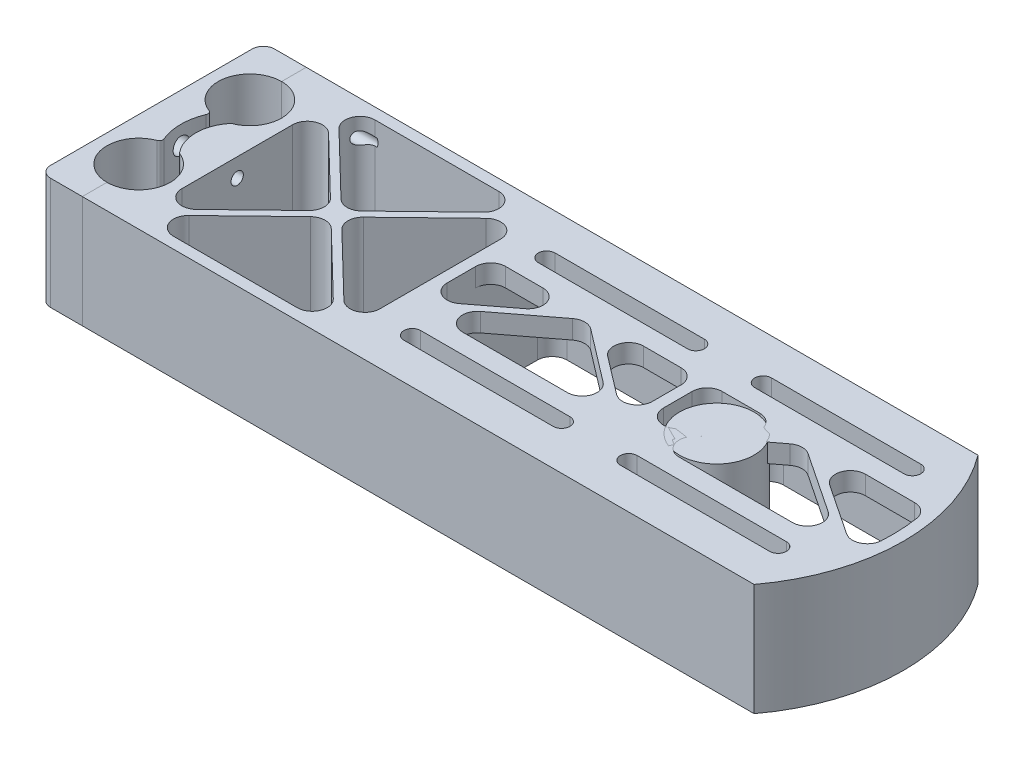
from build123d import *

# Parameters (mm, degrees)
EXTRUDE_1_DEPTH            = 30
CUT_EXTRUDE_1_DEPTH        = 31
TEMP_R                     = 10
EXTRUDE_2_DEPTH            = 30
EXTRUDE_3_DEPTH            = 5
EXTRUDE_4_DEPTH            = 30
SKETCH_6_W                 = 3
SKETCH_6_H                 = 54
EXTRUDE_5_DEPTH            = 30
EXTRUDE_6_DEPTH            = 30
SKETCH_9_W                 = 3
SKETCH_9_H                 = 54
EXTRUDE_8_DEPTH            = 25
EXTRUDE_8_DEPTH_BACK       = 5
EXTRUDE_7_DEPTH            = 5
FILLET_1_R                 = 4
FILLET_2_R                 = 4
FILLET_3_R                 = 4
EXTRUDE_9_DEPTH            = 5
CUT_EXTRUDE_4_DEPTH        = 31
EXTRUDE_10_DEPTH           = 30
FILLET_4_R                 = 4
M4X0_71_AT_2_COUNT         = 2
M4X0_71_AT_2_PITCH         = 25.75
M4X0_71_AT_3_COUNT         = 2
M4X0_71_AT_3_PITCH         = 51.5
M4X0_71_AT_4_COUNT         = 2
M4X0_71_AT_4_PITCH         = 55.247171873
M4X0_71_AT_5_COUNT         = 2
M4X0_71_AT_5_PITCH         = 32.60463924
M4X0_71_AT_6_COUNT         = 2
M4X0_71_AT_6_PITCH         = 20
EXTRUDE_11_DEPTH           = 30
EXTRUDE_12_DEPTH           = 30
CUT_EXTRUDE_6_DEPTH        = 31.0000001
FILLET_8_R                 = 1
FILLET_9_R                 = 1
HOLE_WIZARD_M41_AT_2_COUNT = 2
HOLE_WIZARD_M41_AT_2_PITCH = 20
FILLET_10_R                = 3


with BuildPart() as part:
    # Эскиз1 → Бобышка-Вытянуть1 (new body)
    with BuildSketch(Plane(origin=(0, 0, 0), x_dir=(1, 0, 0), z_dir=(0, 1, 0))):
        with BuildLine():
            Line((0, 60), (180, 60))
            ThreePointArc((180, 60), (190, 30), (180, 0))
            Line((180, 0), (0, 0))
            Line((0, 0), (0, 8))
            ThreePointArc((0, 8), (7.1, 15.1), (0, 22.2))
            Line((0, 22.2), (0, 37.8))
            ThreePointArc((0, 37.8), (7.1, 44.9), (0, 52))
            Line((0, 52), (0, 60))
        make_face()
    extrude(amount=EXTRUDE_1_DEPTH)

    # Эскиз2 → Вырез-Вытянуть1 (cut, through all)
    with BuildSketch(Plane(origin=(0, 30, 0), x_dir=(1, 0, 0), z_dir=(0, 1, 0))):
        with BuildLine():
            Line((3, 3), (178.470768123, 3))
            ThreePointArc((178.470768123, 3), (187, 30), (178.470768123, 57))
            Line((178.470768123, 57), (3, 57))
            Line((3, 57), (3, 54.544169223))
            ThreePointArc((3, 54.544169223), (10.1, 44.9), (3, 35.255830777))
            Line((3, 35.255830777), (3, 24.744169223))
            ThreePointArc((3, 24.744169223), (10.1, 15.1), (3, 5.455830777))
            Line((3, 5.455830777), (3, 3))
        make_face()
    extrude(amount=-CUT_EXTRUDE_1_DEPTH, mode=Mode.SUBTRACT)

    # Эскиз3 → Бобышка-Вытянуть3 (add)
    with BuildSketch(Plane(origin=(0, 30, 0), x_dir=(1, 0, 0), z_dir=(0, 1, 0))):
        with BuildLine():
            Line((178.470768123, 57), (68.916586692, 57))
            Line((68.916586692, 57), (68.916586692, 40.5))
            Line((68.916586692, 40.5), (185.812116301, 40.5))
            ThreePointArc((185.812116301, 40.5), (182.941397878, 49.105924428), (178.470768123, 57))
        make_face()
        with BuildLine():
            Line((116.416586692, 43.5), (76.416586692, 43.5))
            ThreePointArc((76.416586692, 43.5), (71.916586692, 48), (76.416586692, 52.5))
            Line((76.416586692, 52.5), (116.416586692, 52.5))
            ThreePointArc((116.416586692, 52.5), (120.916586692, 48), (116.416586692, 43.5))
        make_face(mode=Mode.SUBTRACT)
        with BuildLine():
            ThreePointArc((174.416586692, 52.5), (178.916586692, 48), (174.416586692, 43.5))
            Line((174.416586692, 43.5), (134.416586692, 43.5))
            ThreePointArc((134.416586692, 43.5), (129.916586692, 48), (134.416586692, 52.5))
            Line((134.416586692, 52.5), (174.416586692, 52.5))
        make_face(mode=Mode.SUBTRACT)
        with BuildLine():
            ThreePointArc((178.470768123, 3), (182.941397878, 10.894075572), (185.812116301, 19.5))
            Line((185.812116301, 19.5), (68.916586692, 19.5))
            Line((68.916586692, 19.5), (68.916586692, 3))
            Line((68.916586692, 3), (178.470768123, 3))
        make_face()
        with BuildLine():
            ThreePointArc((76.416586692, 7.5), (71.916586692, 12), (76.416586692, 16.5))
            Line((76.416586692, 16.5), (116.416586692, 16.5))
            ThreePointArc((116.416586692, 16.5), (120.916586692, 12), (116.416586692, 7.5))
            Line((116.416586692, 7.5), (76.416586692, 7.5))
        make_face(mode=Mode.SUBTRACT)
        with BuildLine():
            Line((134.416586692, 16.5), (174.416586692, 16.5))
            ThreePointArc((174.416586692, 16.5), (178.916586692, 12), (174.416586692, 7.5))
            Line((174.416586692, 7.5), (134.416586692, 7.5))
            ThreePointArc((134.416586692, 7.5), (129.916586692, 12), (134.416586692, 16.5))
        make_face(mode=Mode.SUBTRACT)
    extrude(amount=-EXTRUDE_3_DEPTH)

    # Эскиз4 → Бобышка-Вытянуть4 (add, through all)
    with BuildSketch(Plane(origin=(0, 30, 0), x_dir=(1, 0, 0), z_dir=(0, 1, 0))):
        with BuildLine():
            Line((10.1, 57), (3, 57))
            Line((3, 57), (3, 54.544169223))
            ThreePointArc((3, 54.544169223), (8.133572401, 50.887904475), (10.1, 44.9))
            Line((10.1, 44.9), (10.1, 57))
        make_face()
        with BuildLine():
            Line((10.1, 15.099999916), (10.1, 44.9))
            ThreePointArc((10.1, 44.9), (8.133572401, 38.912095525), (3, 35.255830777))
            Line((3, 35.255830777), (3, 24.744169223))
            ThreePointArc((3, 24.744169223), (8.133572426, 21.087904441), (10.1, 15.099999916))
        make_face()
        with BuildLine():
            Line((10.1, 3), (10.1, 15.099999916))
            ThreePointArc((10.1, 15.099999916), (8.133572376, 9.112095491), (3, 5.455830777))
            Line((3, 5.455830777), (3, 3))
            Line((3, 3), (10.1, 3))
        make_face()
    extrude(amount=-EXTRUDE_4_DEPTH)

    # Эскиз6 → Бобышка-Вытянуть5 (add, through all)
    with BuildSketch(Plane(origin=(0, 30, 0), x_dir=(1, 0, 0), z_dir=(0, 1, 0))):
        with Locations((67.416586692, 30)):
            Rectangle(SKETCH_6_W, SKETCH_6_H)
    extrude(amount=-EXTRUDE_5_DEPTH)

    # Эскиз7 → Бобышка-Вытянуть6 (add, through all)
    with BuildSketch(Plane(origin=(0, 30, 0), x_dir=(1, 0, 0), z_dir=(0, 1, 0))):
        Polygon((10.1, 55.608609353), (36.57009563, 30), (10.1, 4.391390647), (10.1, 3), (11.538197716, 3), (38.008293346, 28.608609353), (64.478388976, 3), (65.916586692, 3), (65.916586692, 4.391390647), (39.446491062, 30), (65.916586692, 55.608609353), (65.916586692, 57), (64.478388976, 57), (38.008293346, 31.391390647), (11.538197716, 57), (10.1, 57), align=None)
    extrude(amount=-EXTRUDE_6_DEPTH)

    # Эскиз9 → Бобышка-Вытянуть8 (add, two sides)
    with BuildSketch(Plane.XZ.offset(-25)) as extrude_8_sk:
        with Locations((125.416586692, -30)):
            Rectangle(SKETCH_9_W, SKETCH_9_H)
    extrude(amount=EXTRUDE_8_DEPTH)
    extrude(extrude_8_sk.sketch, amount=-EXTRUDE_8_DEPTH_BACK)

    # Эскиз8 → Бобышка-Вытянуть7 (add)
    with BuildSketch(Plane(origin=(0, 30, 0), x_dir=(1, 0, 0), z_dir=(0, 1, 0))):
        Polygon((70.564267671, 19.5), (96.416586692, 39.241770889), (122.268905713, 19.5), (123.916586692, 19.5), (123.916586692, 20.758229111), (98.064267671, 40.5), (94.768905713, 40.5), (68.916586692, 20.758229111), (68.916586692, 19.5), align=None)
        with BuildLine():
            Line((128.569887735, 19.5), (154.477979009, 39.178204914))
            Line((154.477979009, 39.178204914), (184.008770478, 19.5))
            Line((184.008770478, 19.5), (185.812116301, 19.5))
            ThreePointArc((185.812116301, 19.5), (185.929117822, 20.024222532), (186.040120933, 20.549747915))
            Line((186.040120933, 20.549747915), (156.101072293, 40.5))
            Line((156.101072293, 40.5), (152.911636662, 40.5))
            Line((152.911636662, 40.5), (126.916586692, 20.755746568))
            Line((126.916586692, 20.755746568), (126.916586692, 19.5))
            Line((126.916586692, 19.5), (128.569887735, 19.5))
        make_face()
    extrude(amount=-EXTRUDE_7_DEPTH)

    # Скругление1
    fillet_1_edges = [part.edges().sort_by_distance(p)[0] for p in [
        (36.57009563, 15, -30),
        (11.538197716, 15, -57),
        (38.008293346, 15, -31.391390647),
        (64.478388976, 15, -57),
        (65.916586692, 15, -55.608609353),
        (39.446491062, 15, -30),
        (65.916586692, 15, -4.391390647),
        (64.478388976, 15, -3),
        (38.008293346, 15, -28.608609353),
        (11.538197716, 15, -3),
    ]]
    fillet(fillet_1_edges, radius=FILLET_1_R)

    # Скругление2
    fillet_2_edges = [part.edges().sort_by_distance(p)[0] for p in [
        (68.916586692, 12.5, -57),
        (68.916586692, 12.5, -3),
        (123.916586692, 12.5, -57),
        (126.916586692, 12.5, -3),
        (123.916586692, 12.5, -3),
        (126.916586692, 12.5, -57),
        (178.470768123, 12.5, -57),
        (178.470768123, 12.5, -3),
    ]]
    fillet(fillet_2_edges, radius=FILLET_2_R)

    # Скругление3
    fillet_3_edges = [part.edges().sort_by_distance(p)[0] for p in [
        (123.916586692, 27.5, -40.5),
        (126.916586692, 27.5, -40.5),
        (70.564267671, 27.5, -19.5),
        (68.916586692, 27.5, -20.758229111),
        (94.768905713, 27.5, -40.5),
        (98.064267671, 27.5, -40.5),
        (123.916586692, 27.5, -20.758229111),
        (122.268905713, 27.5, -19.5),
        (96.416586692, 27.5, -39.241770889),
        (128.569887735, 27.5, -19.5),
        (126.916586692, 27.5, -20.755746568),
        (152.911636662, 27.5, -40.5),
        (156.101072293, 27.5, -40.5),
        (186.040120933, 27.5, -20.549747915),
        (184.008770478, 27.5, -19.5),
        (154.477979009, 27.5, -39.178204914),
        (68.916586692, 27.5, -40.5),
        (185.812116301, 27.5, -40.5),
    ]]
    fillet(fillet_3_edges, radius=FILLET_3_R)

    # Эскиз10 → Бобышка-Вытянуть9 (add)
    with BuildSketch(Plane(origin=(0, 30, 0), x_dir=(1, 0, 0), z_dir=(0, 1, 0))):
        with BuildLine():
            Line((76.416586692, 52.5), (116.416586692, 52.5))
            ThreePointArc((116.416586692, 52.5), (120.916586692, 48), (116.416586692, 43.5))
            Line((116.416586692, 43.5), (76.416586692, 43.5))
            ThreePointArc((76.416586692, 43.5), (71.916586692, 48), (76.416586692, 52.5))
        make_face()
        with BuildLine():
            Line((116.416586692, 50.25), (76.416586692, 50.25))
            ThreePointArc((76.416586692, 50.25), (74.166586692, 48), (76.416586692, 45.75))
            Line((76.416586692, 45.75), (116.416586692, 45.75))
            ThreePointArc((116.416586692, 45.75), (118.666586692, 48), (116.416586692, 50.25))
        make_face(mode=Mode.SUBTRACT)
        with BuildLine():
            Line((174.416586692, 52.5), (134.416586692, 52.5))
            ThreePointArc((134.416586692, 52.5), (129.916586692, 48), (134.416586692, 43.5))
            Line((134.416586692, 43.5), (174.416586692, 43.5))
            ThreePointArc((174.416586692, 43.5), (178.916586692, 48), (174.416586692, 52.5))
        make_face()
        with BuildLine():
            Line((174.416586692, 45.75), (134.416586692, 45.75))
            ThreePointArc((134.416586692, 45.75), (132.166586692, 48), (134.416586692, 50.25))
            Line((134.416586692, 50.25), (174.416586692, 50.25))
            ThreePointArc((174.416586692, 50.25), (176.666586692, 48), (174.416586692, 45.75))
        make_face(mode=Mode.SUBTRACT)
        with BuildLine():
            Line((76.416586692, 16.5), (116.416586692, 16.5))
            ThreePointArc((116.416586692, 16.5), (120.916586692, 12), (116.416586692, 7.5))
            Line((116.416586692, 7.5), (76.416586692, 7.5))
            ThreePointArc((76.416586692, 7.5), (71.916586692, 12), (76.416586692, 16.5))
        make_face()
        with BuildLine():
            Line((76.416586692, 9.75), (116.416586692, 9.75))
            ThreePointArc((116.416586692, 9.75), (118.666586692, 12), (116.416586692, 14.25))
            Line((116.416586692, 14.25), (76.416586692, 14.25))
            ThreePointArc((76.416586692, 14.25), (74.166586692, 12), (76.416586692, 9.75))
        make_face(mode=Mode.SUBTRACT)
        with BuildLine():
            Line((174.416586692, 16.5), (134.416586692, 16.5))
            ThreePointArc((134.416586692, 16.5), (129.916586692, 12), (134.416586692, 7.5))
            Line((134.416586692, 7.5), (174.416586692, 7.5))
            ThreePointArc((174.416586692, 7.5), (178.916586692, 12), (174.416586692, 16.5))
        make_face()
        with BuildLine():
            Line((174.416586692, 14.25), (134.416586692, 14.25))
            ThreePointArc((134.416586692, 14.25), (132.166586692, 12), (134.416586692, 9.75))
            Line((134.416586692, 9.75), (174.416586692, 9.75))
            ThreePointArc((174.416586692, 9.75), (176.666586692, 12), (174.416586692, 14.25))
        make_face(mode=Mode.SUBTRACT)
    extrude(amount=-EXTRUDE_9_DEPTH)

    # Эскиз16 → Вырез-Вытянуть4 (cut, through all)
    with BuildSketch(Plane(origin=(0, 30, 0), x_dir=(1, 0, 0), z_dir=(0, 1, 0))):
        with BuildLine():
            Line((0, 8), (0, 6.6))
            ThreePointArc((0, 6.6), (8.5, 15.1), (0, 23.6))
            Line((0, 23.6), (0, 22.2))
            ThreePointArc((0, 22.2), (7.1, 15.1), (0, 8))
        make_face()
        with BuildLine():
            Line((0, 37.8), (0, 36.4))
            ThreePointArc((0, 36.4), (8.5, 44.9), (0, 53.4))
            Line((0, 53.4), (0, 52))
            ThreePointArc((0, 52), (7.1, 44.9), (0, 37.8))
        make_face()
    extrude(amount=-CUT_EXTRUDE_4_DEPTH, mode=Mode.SUBTRACT)

    # Эскиз17 → Бобышка-Вытянуть10 (add, through all)
    with BuildSketch(Plane(origin=(0, 30, 0), x_dir=(1, 0, 0), z_dir=(0, 1, 0))):
        Polygon((11.5, 54.254173253), (11.5, 5.745826747), (10.1, 4.391390647), (10.1, 55.608609353), align=None)
    extrude(amount=-EXTRUDE_10_DEPTH)

    # Скругление4
    fillet_4_edges = [part.edges().sort_by_distance(p)[0] for p in [
        (11.5, 15, -54.254173253),
        (11.5, 15, -5.745826747),
    ]]
    fillet(fillet_4_edges, radius=FILLET_4_R)

    # Эскиз14 → Отверстие обработанное метчиком M4x0.71 (revolve, cut)
    with BuildSketch(Plane(origin=(0, 25, -55.75), x_dir=(0, 0, 1), z_dir=(0, 1, 0))):
        Polygon((0, 0), (0, 22.991420021), (1.65, 22), (1.65, 0), align=None)
    m4x0_71 = revolve(axis=Axis((-6.35, 25, -55.75), (1, 0, 0)), mode=Mode.SUBTRACT)

    # Отверстие обработанное метчиком M4x0.71 at 2: Отверстие обработанное метчиком M4x0.71 ×2
    with Locations(*[(0, 0, i * M4X0_71_AT_2_PITCH) for i in range(1, M4X0_71_AT_2_COUNT)]):
        add(m4x0_71, mode=Mode.SUBTRACT)

    # Отверстие обработанное метчиком M4x0.71 at 3: Отверстие обработанное метчиком M4x0.71 ×2
    with Locations(*[(0, 0, i * M4X0_71_AT_3_PITCH) for i in range(1, M4X0_71_AT_3_COUNT)]):
        add(m4x0_71, mode=Mode.SUBTRACT)

    # Отверстие обработанное метчиком M4x0.71 at 4: Отверстие обработанное метчиком M4x0.71 ×2
    with Locations(*[Vector(0, -0.362009481, 0.932174413) * (i * M4X0_71_AT_4_PITCH) for i in range(1, M4X0_71_AT_4_COUNT)]):
        add(m4x0_71, mode=Mode.SUBTRACT)

    # Отверстие обработанное метчиком M4x0.71 at 5: Отверстие обработанное метчиком M4x0.71 ×2
    with Locations(*[Vector(0, -0.613409639, 0.789764911) * (i * M4X0_71_AT_5_PITCH) for i in range(1, M4X0_71_AT_5_COUNT)]):
        add(m4x0_71, mode=Mode.SUBTRACT)

    # Отверстие обработанное метчиком M4x0.71 at 6: Отверстие обработанное метчиком M4x0.71 ×2
    with Locations(*[(0, -i * M4X0_71_AT_6_PITCH, 0) for i in range(1, M4X0_71_AT_6_COUNT)]):
        add(m4x0_71, mode=Mode.SUBTRACT)


with BuildPart() as body_2:
    # Temp → Бобышка-Вытянуть2 (new body)
    with BuildSketch(Plane(origin=(0, 30, 0), x_dir=(1, 0, 0), z_dir=(0, 1, 0))):
        with Locations((140, 30)):
            Circle(TEMP_R)
    extrude(amount=-EXTRUDE_2_DEPTH)


with BuildPart() as body_3:
    # Эскиз18 → Бобышка-Вытянуть11 (new body, through all)
    with BuildSketch(Plane.XZ):
        with BuildLine():
            Line((0, -6.6), (0, 0))
            Line((0, 0), (-11.5, 0))
            Line((-11.5, 0), (-11.5, -15.1))
            ThreePointArc((-11.5, -15.1), (-10.173494975, -20.461902647), (-6.5, -24.586832981))
            Line((-6.5, -24.586832981), (-6.5, -35.413167019))
            ThreePointArc((-6.5, -35.413167019), (-10.173494975, -39.538097353), (-11.5, -44.9))
            Line((-11.5, -44.9), (-11.5, -60))
            Line((-11.5, -60), (0, -60))
            Line((0, -60), (0, -53.4))
            ThreePointArc((0, -53.4), (-8.5, -44.9), (0, -36.4))
            Line((0, -36.4), (0, -23.6))
            ThreePointArc((0, -23.6), (-8.5, -15.1), (0, -6.6))
        make_face()
    extrude(amount=-EXTRUDE_11_DEPTH)

    # Эскиз21 → Бобышка-Вытянуть12 (add, through all)
    with BuildSketch(Plane.XZ):
        Polygon((-11.5, -15.1), (-11.5, -44.9), (-10.173494975, -44.9), (-4.755372737, -34.223531575), (-4.755372737, -23.623411539), align=None)
    extrude(amount=-EXTRUDE_12_DEPTH)


with BuildPart() as cut_extrude_6_tool:
    # Эскиз22 → Вырез-Вытянуть6 (new body, through all)
    with BuildSketch(Plane.XZ):
        with BuildLine():
            ThreePointArc((-2, -36.638644179), (-3.586685858, -30), (-2, -23.361355821))
            ThreePointArc((-2, -23.361355821), (-1.00709372, -23.540128094), (0, -23.6))
            ThreePointArc((0, -23.6), (1.510109226, -23.464781535), (2.972172651, -23.063428265))
            ThreePointArc((2.972172651, -23.063428265), (0.413314142, -30), (2.972172651, -36.936571735))
            ThreePointArc((2.972172651, -36.936571735), (1.510109226, -36.535218465), (0, -36.4))
            ThreePointArc((0, -36.4), (-1.00709372, -36.459871906), (-2, -36.638644179))
        make_face()
    extrude(amount=-CUT_EXTRUDE_6_DEPTH)


with BuildPart() as part_1:
    add(part.part)

    # Вырез-Вытянуть6: cut by cut_extrude_6_tool
    add(cut_extrude_6_tool.part, mode=Mode.SUBTRACT)

    # Скругление9
    fillet_9_edges = [part_1.edges().sort_by_distance(p)[0] for p in [
        (2.972172651, 15, -36.936571735),
        (2.972172651, 15, -23.063428265),
    ]]
    fillet(fillet_9_edges, radius=FILLET_9_R)


with BuildPart() as body_3_1:
    add(body_3.part)

    # Вырез-Вытянуть6: cut by cut_extrude_6_tool
    add(cut_extrude_6_tool.part, mode=Mode.SUBTRACT)

    # Скругление8
    fillet_8_edges = [body_3_1.edges().sort_by_distance(p)[0] for p in [
        (-2, 15, -23.361355821),
        (-2, 15, -36.638644179),
    ]]
    fillet(fillet_8_edges, radius=FILLET_8_R)

    # Эскиз24 → Цековка для винта с внутренним шестигранником M41 (revolve, cut)
    with BuildSketch(Plane(origin=(-11.5, 5, -30), x_dir=(0, 0, 1), z_dir=(0, 1, 0))):
        Polygon((0, 0), (0, 10.351936393), (2.25, 9), (2.25, 4), (4, 4), (4, 0), align=None)
    hole_wizard_m41 = revolve(axis=Axis((-17.85, 5, -30), (1, 0, 0)), mode=Mode.SUBTRACT)

    # Цековка для винта с внутренним шестигранником M41 at 2: Цековка для винта с внутренним шестигранником M41 ×2
    with Locations(*[(0, i * HOLE_WIZARD_M41_AT_2_PITCH, 0) for i in range(1, HOLE_WIZARD_M41_AT_2_COUNT)]):
        add(hole_wizard_m41, mode=Mode.SUBTRACT)

    # Скругление10
    fillet_10_edges = [body_3_1.edges().sort_by_distance(p)[0] for p in [
        (-11.5, 15, -60),
        (-11.5, 15, 0),
    ]]
    fillet(fillet_10_edges, radius=FILLET_10_R)


solid = Compound([body_2.part, part_1.part, body_3_1.part])
